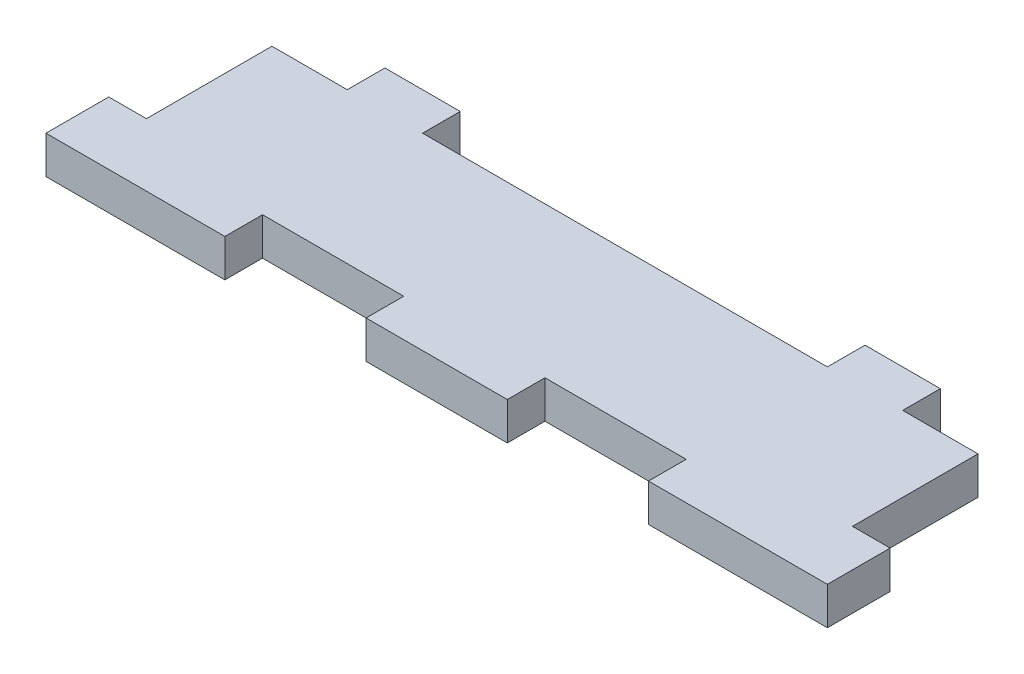
from build123d import *

# Parameters (mm, degrees)
SKETCH1_W           = 112.5
SKETCH1_H           = 24
BOSS_EXTRUDE1_DEPTH = 6
SKETCH2_W           = 22.5
SKETCH2_H           = 6
BOSS_EXTRUDE2_DEPTH = 6
SKETCH3_W           = 10
SKETCH3_H           = 6
BOSS_EXTRUDE3_DEPTH = 6
SKETCH4_W           = 12
SKETCH4_H           = 6
BOSS_EXTRUDE4_DEPTH = 6


with BuildPart() as part:
    # Sketch1 → Boss-Extrude1 (new body)
    with BuildSketch(Plane(origin=(0, 0, 0), x_dir=(1, 0, 0), z_dir=(0, 1, 0))):
        Rectangle(SKETCH1_W, SKETCH1_H)
    extrude(amount=BOSS_EXTRUDE1_DEPTH)

    # Sketch2 → Boss-Extrude2 (add)
    with BuildSketch(Plane.XY.offset(12)):
        with Locations((-45, 3)):
            Rectangle(SKETCH2_W, SKETCH2_H)
        with Locations((0, 3)):
            Rectangle(SKETCH2_W, SKETCH2_H)
        with Locations((45, 3)):
            Rectangle(SKETCH2_W, SKETCH2_H)
    extrude(amount=BOSS_EXTRUDE2_DEPTH)

    # Sketch3 → Boss-Extrude3 (add)
    with BuildSketch(Plane(origin=(56.25, 0, 0), x_dir=(0, 0, -1), z_dir=(1, 0, 0))):
        with Locations((-13, 3)):
            Rectangle(SKETCH3_W, SKETCH3_H)
    boss_extrude3 = extrude(amount=BOSS_EXTRUDE3_DEPTH)

    # Mirror1: Boss-Extrude3 across plane
    add(boss_extrude3.mirror(Plane(origin=(0, 0, 0), x_dir=(0, 0, 1), z_dir=(1, 0, 0))))

    # Sketch4 → Boss-Extrude4 (add)
    with BuildSketch(Plane(origin=(0, 0, -12), x_dir=(-1, 0, 0), z_dir=(0, 0, -1))):
        with Locations((-38.25, 3)):
            Rectangle(SKETCH4_W, SKETCH4_H)
        with Locations((38.25, 3)):
            Rectangle(SKETCH4_W, SKETCH4_H)
    extrude(amount=BOSS_EXTRUDE4_DEPTH)


solid = part.part
